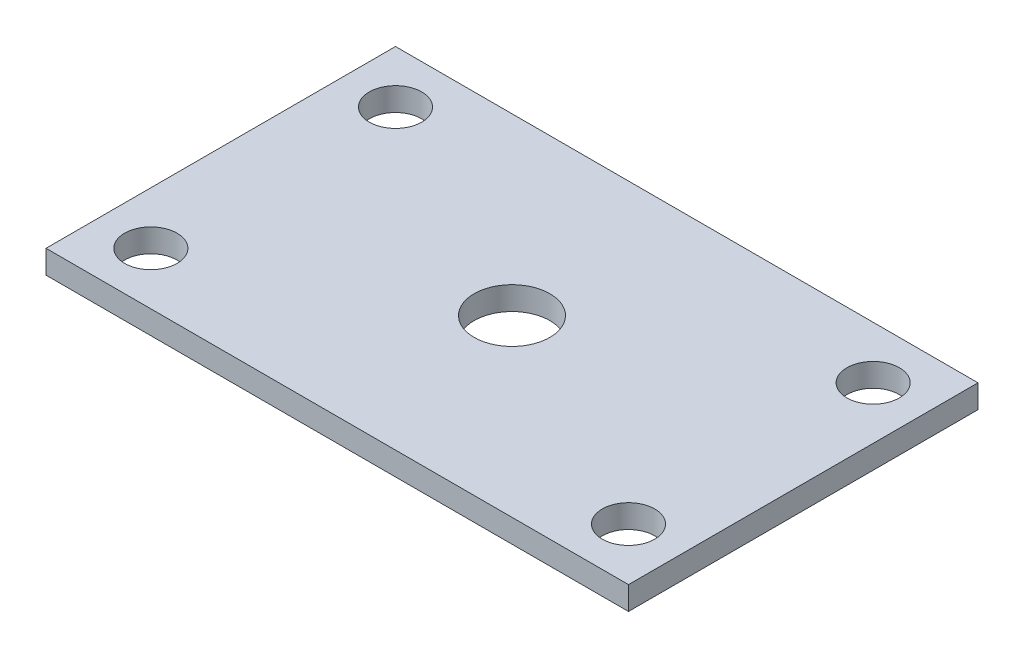
from build123d import *

# Parameters (mm, degrees)
SKETCH1_W           = 100
SKETCH1_H           = 60
SKETCH1_R           = 6.5
BOSS_EXTRUDE1_DEPTH = 4
SKETCH2_R           = 4.5
CUT_EXTRUDE1_DEPTH  = 5


with BuildPart() as part:
    # Sketch1 → Boss-Extrude1 (new body)
    with BuildSketch(Plane(origin=(0, 0, 0), x_dir=(1, 0, 0), z_dir=(0, 1, 0))):
        Rectangle(SKETCH1_W, SKETCH1_H)
        Circle(SKETCH1_R, mode=Mode.SUBTRACT)
    extrude(amount=BOSS_EXTRUDE1_DEPTH)

    # Sketch2 → Cut-Extrude1 (cut, through all)
    with BuildSketch(Plane(origin=(0, 4, 0), x_dir=(1, 0, 0), z_dir=(0, 1, 0))):
        with Locations((-41, 21)):
            Circle(SKETCH2_R)
        with Locations((41, 21)):
            Circle(SKETCH2_R)
        with Locations((41, -21)):
            Circle(SKETCH2_R)
        with Locations((-41, -21)):
            Circle(SKETCH2_R)
    extrude(amount=-CUT_EXTRUDE1_DEPTH, mode=Mode.SUBTRACT)


solid = part.part
